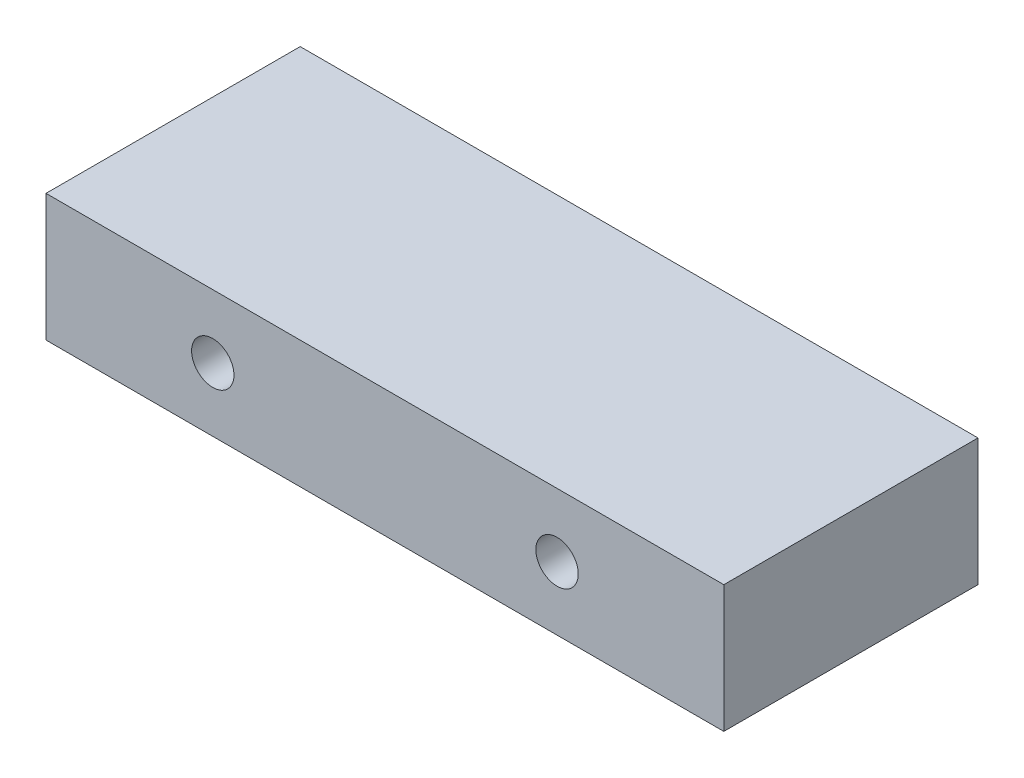
from build123d import *

# Parameters (mm, degrees)
SKETCH1_W        = 101.6
SKETCH1_H        = 19.05
SKETCH1_R        = 3.175
EXTRUSION1_DEPTH = 38.1


with BuildPart() as part:
    # Sketch1 → Extrusion1 (new body)
    with BuildSketch(Plane.XY):
        with Locations((50.8, 9.525)):
            Rectangle(SKETCH1_W, SKETCH1_H)
        with Locations((76.603920836, 9.525)):
            Circle(SKETCH1_R, mode=Mode.SUBTRACT)
        with Locations((24.997072946, 9.525)):
            Circle(SKETCH1_R, mode=Mode.SUBTRACT)
    extrude(amount=EXTRUSION1_DEPTH)


solid = part.part
